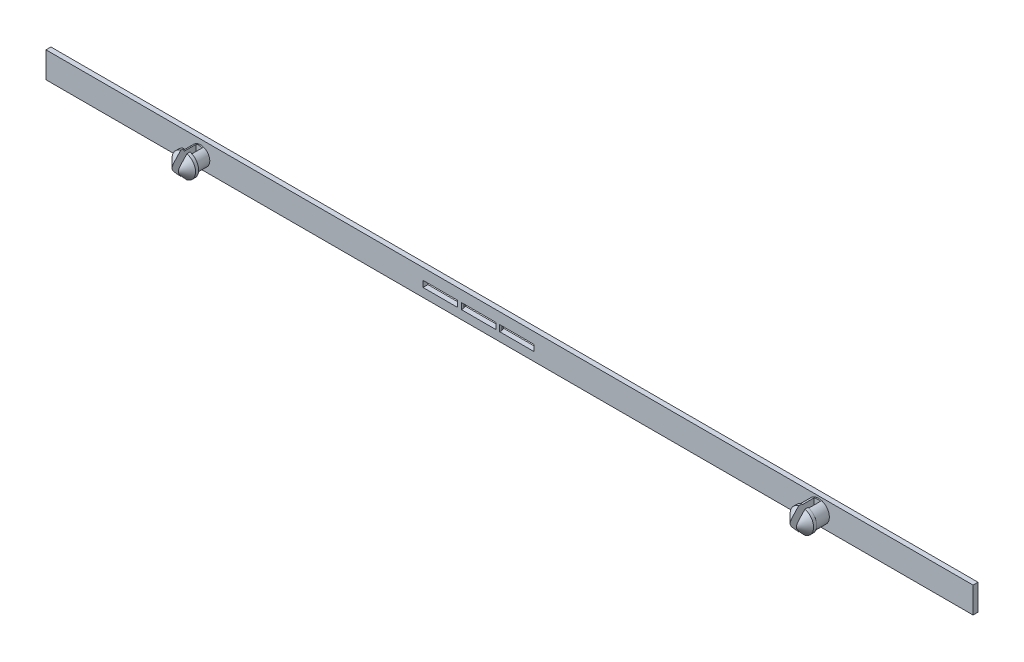
from build123d import *

# Parameters (mm, degrees)
SKICA2_W                 = 150
SKICA2_H                 = 4.2
SKICA2_W_2               = 18
SKICA2_H_2               = 1
P_IDAT_VYSUNUT_M2_DEPTH  = 0.8
SKICA3_R                 = 1.5
SKICA3_R_2               = 1.75
P_IDAT_VYSUNUT_M3_DEPTH  = 2.2
SKICA4_W                 = 0.6
SKICA4_H                 = 1
SKICA4_H_2               = 1.2
P_IDAT_VYSUNUT_M4_DEPTH  = 0.8
ZKOSEN_1_SIZE            = 0.4
ZKOSEN_1_SIZE2           = 0.145588094
ZKOSEN_1_PART_2_SIZE     = 0.4
ZKOSEN_1_PART_2_SIZE2    = 0.145588094
ZKOSEN_1_PART_3_SIZE     = 0.4
ZKOSEN_1_PART_3_SIZE2    = 0.145588094
ZKOSEN_1_PART_4_SIZE     = 0.4
ZKOSEN_1_PART_4_SIZE2    = 0.145588094
SKICA5_R                 = 1.9
P_IDAT_VYSUNUT_M5_DEPTH  = 2
ZKOSEN_2_SIZE            = 1.5
SKICA7_W                 = 1
SKICA7_H                 = 5
ODEBRAT_VYSUNUT_M1_DEPTH = 4


with BuildPart() as part:
    # Skica2 → Přidat vysunutím2 (new body)
    with BuildSketch(Plane.XY):
        Rectangle(SKICA2_W, SKICA2_H)
        with Locations((-5, -0.2)):
            Rectangle(SKICA2_W_2, SKICA2_H_2, mode=Mode.SUBTRACT)
    extrude(amount=P_IDAT_VYSUNUT_M2_DEPTH)

    # Skica3 → Přidat vysunutím3 (add)
    with BuildSketch(Plane.XY.offset(0.8)):
        with Locations((-50, -0.2)):
            Circle(SKICA3_R)
        with Locations((50, 0)):
            Circle(SKICA3_R_2)
    extrude(amount=P_IDAT_VYSUNUT_M3_DEPTH)

    # Skica4 → Přidat vysunutím4 (add)
    with BuildSketch(Plane(origin=(0, 0, 0), x_dir=(-1, 0, 0), z_dir=(0, 0, -1))):
        with Locations((1.9, -0.2)):
            Rectangle(SKICA4_W, SKICA4_H)
        with Locations((8.1, -0.1)):
            Rectangle(SKICA4_W, SKICA4_H_2)
    extrude(amount=-P_IDAT_VYSUNUT_M4_DEPTH)

    # Zkosení1
    zkosen_1_edges = [part.edges().sort_by_distance(p)[0] for p in [
        (-1.6, -0.2, 0),
    ]]
    zkosen_1_side = [part.faces().sort_by_distance(p)[0] for p in [
        (-1.6, -0.2, 0.4),
    ]]
    chamfer(zkosen_1_edges, length=ZKOSEN_1_SIZE, length2=ZKOSEN_1_SIZE2, reference=zkosen_1_side[0])

    # Zkosení1 part 2
    zkosen_1_part_2_edges = [part.edges().sort_by_distance(p)[0] for p in [
        (-2.2, -0.2, 0),
    ]]
    zkosen_1_part_2_side = [part.faces().sort_by_distance(p)[0] for p in [
        (-2.2, -0.2, 0.4),
    ]]
    chamfer(zkosen_1_part_2_edges, length=ZKOSEN_1_PART_2_SIZE, length2=ZKOSEN_1_PART_2_SIZE2, reference=zkosen_1_part_2_side[0])

    # Zkosení1 part 3
    zkosen_1_part_3_edges = [part.edges().sort_by_distance(p)[0] for p in [
        (-8.4, -0.2, 0),
    ]]
    zkosen_1_part_3_side = [part.faces().sort_by_distance(p)[0] for p in [
        (-8.4, -0.2, 0.4),
    ]]
    chamfer(zkosen_1_part_3_edges, length=ZKOSEN_1_PART_3_SIZE, length2=ZKOSEN_1_PART_3_SIZE2, reference=zkosen_1_part_3_side[0])

    # Zkosení1 part 4
    zkosen_1_part_4_edges = [part.edges().sort_by_distance(p)[0] for p in [
        (-7.8, -0.2, 0),
    ]]
    zkosen_1_part_4_side = [part.faces().sort_by_distance(p)[0] for p in [
        (-7.8, -0.2, 0.4),
    ]]
    chamfer(zkosen_1_part_4_edges, length=ZKOSEN_1_PART_4_SIZE, length2=ZKOSEN_1_PART_4_SIZE2, reference=zkosen_1_part_4_side[0])

    # Skica5 → Přidat vysunutím5 (add)
    with BuildSketch(Plane.XY.offset(3)):
        with Locations((-50, -0.2)):
            Circle(SKICA5_R)
        with Locations((50, 0)):
            Circle(SKICA5_R)
    extrude(amount=P_IDAT_VYSUNUT_M5_DEPTH)

    # Zkosení2
    zkosen_2_edges = [part.edges().sort_by_distance(p)[0] for p in [
        (-51.9, -0.2, 5),
        (48.1, 0, 5),
    ]]
    chamfer(zkosen_2_edges, length=ZKOSEN_2_SIZE)

    # Skica7 → Odebrat vysunutím1 (cut)
    with BuildSketch(Plane.XY.offset(5)):
        with Locations((-50, -0.2)):
            Rectangle(SKICA7_W, SKICA7_H)
        with Locations((50, 0)):
            Rectangle(SKICA7_W, SKICA7_H)
    extrude(amount=-ODEBRAT_VYSUNUT_M1_DEPTH, mode=Mode.SUBTRACT)


solid = part.part
